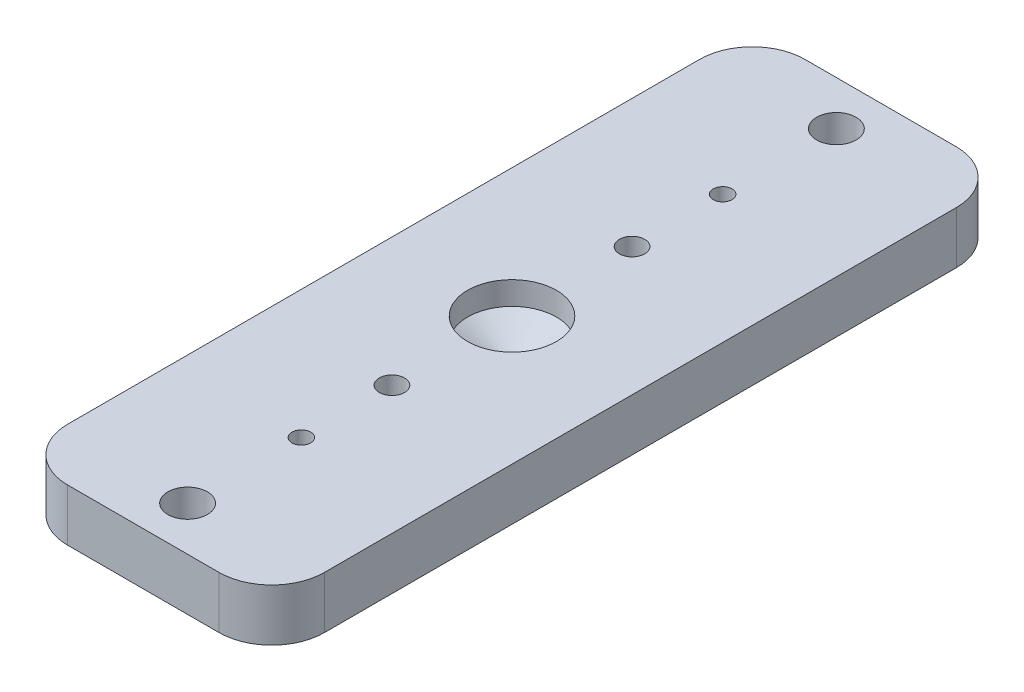
from build123d import *

# Parameters (mm, degrees)
SKETCH1_W                   = 30.95625
SKETCH1_H                   = 88.9
BOSS_EXTRUDE1_DEPTH         = 4.7625
FILLET1_R                   = 6.35
SKETCH6_R                   = 1.524
CUT_EXTRUDE1_DEPTH          = 5.7625
SKETCH7_R                   = 2.38125
CUT_EXTRUDE2_DEPTH          = 5.7625
BOSS_EXTRUDE3_DEPTH         = 1.524
F_4_40_TAPPED_HOLE1_D       = 2.2606
SKETCH10_R                  = 1.524
CUT_EXTRUDE3_DEPTH          = 2.524
SKETCH11_R                  = 3.175
CUT_EXTRUDE4_DEPTH          = 3.302
F_1_2_13_TAPPED_HOLE2_D     = 10.71626
F_1_2_13_TAPPED_HOLE2_DEPTH = 2.794
F_1_2_13_TAPPED_HOLE2_TIP   = 3.219489309


with BuildPart() as part:
    # Sketch1 → Boss-Extrude1 (new body)
    with BuildSketch(Plane(origin=(0, 0, 0), x_dir=(1, 0, 0), z_dir=(0, 1, 0))):
        Rectangle(SKETCH1_W, SKETCH1_H)
    extrude(amount=BOSS_EXTRUDE1_DEPTH)

    # Fillet1
    fillet1_edges = [part.edges().sort_by_distance(p)[0] for p in [
        (15.478125, 2.38125, -44.45),
        (15.478125, 2.38125, 44.45),
        (-15.478125, 2.38125, 44.45),
        (-15.478125, 2.38125, -44.45),
    ]]
    fillet(fillet1_edges, radius=FILLET1_R)

    # Sketch6 → Cut-Extrude1 (cut, through all)
    with BuildSketch(Plane.XZ):
        with Locations((0, 14.478)):
            Circle(SKETCH6_R)
        with Locations((0, -14.478)):
            Circle(SKETCH6_R)
    extrude(amount=-CUT_EXTRUDE1_DEPTH, mode=Mode.SUBTRACT)

    # Sketch7 → Cut-Extrude2 (cut, through all)
    with BuildSketch(Plane.XZ):
        with Locations((0, -39.116)):
            Circle(SKETCH7_R)
        with Locations((0, 39.116)):
            Circle(SKETCH7_R)
    extrude(amount=-CUT_EXTRUDE2_DEPTH, mode=Mode.SUBTRACT)

    # Sketch9 → Boss-Extrude3 (add)
    with BuildSketch(Plane.XZ):
        with BuildLine():
            Line((9.128125, -44.45), (-9.128125, -44.45))
            ThreePointArc((-9.128125, -44.45), (-13.618253061, -42.590128061), (-15.478125, -38.1))
            Line((-15.478125, -38.1), (-15.478125, 38.1))
            ThreePointArc((-15.478125, 38.1), (-13.618253061, 42.590128061), (-9.128125, 44.45))
            Line((-9.128125, 44.45), (9.128125, 44.45))
            ThreePointArc((9.128125, 44.45), (13.618253061, 42.590128061), (15.478125, 38.1))
            Line((15.478125, 38.1), (15.478125, -38.1))
            ThreePointArc((15.478125, -38.1), (13.618253061, -42.590128061), (9.128125, -44.45))
        make_face()
    extrude(amount=BOSS_EXTRUDE3_DEPTH)

    # #4-40 Tapped Hole1 (through all)
    with Locations(Plane(origin=(0, 4.7625, 0), x_dir=(-1, 0, 0), z_dir=(0, 1, 0))):
        with Locations((0, 25.4), (0, -25.4)):
            Hole(F_4_40_TAPPED_HOLE1_D / 2)

    # Sketch10 → Cut-Extrude3 (cut, through all)
    with BuildSketch(Plane(origin=(0, 0, 0), x_dir=(1, 0, 0), z_dir=(0, 1, 0))):
        with Locations((0, -14.478)):
            Circle(SKETCH10_R)
        with Locations((0, 14.478)):
            Circle(SKETCH10_R)
    extrude(amount=-CUT_EXTRUDE3_DEPTH, mode=Mode.SUBTRACT)

    # Sketch11 → Cut-Extrude4 (cut)
    with BuildSketch(Plane.XZ.offset(1.524)):
        with Locations((0, -14.478)):
            Circle(SKETCH11_R)
        with Locations((0, 14.478)):
            Circle(SKETCH11_R)
    extrude(amount=-CUT_EXTRUDE4_DEPTH, mode=Mode.SUBTRACT)

    # 1/2-13 Tapped Hole2
    with Locations(Plane(origin=(0, 4.7625, 0), x_dir=(-1, 0, 0), z_dir=(0, 1, 0))):
        with Locations((0, 0)):
            Hole(F_1_2_13_TAPPED_HOLE2_D / 2, depth=F_1_2_13_TAPPED_HOLE2_DEPTH)
            with Locations((0, 0, -(F_1_2_13_TAPPED_HOLE2_DEPTH + F_1_2_13_TAPPED_HOLE2_TIP / 2))):  # 118° drill point
                Cone(0, F_1_2_13_TAPPED_HOLE2_D / 2, F_1_2_13_TAPPED_HOLE2_TIP, mode=Mode.SUBTRACT)


solid = part.part
